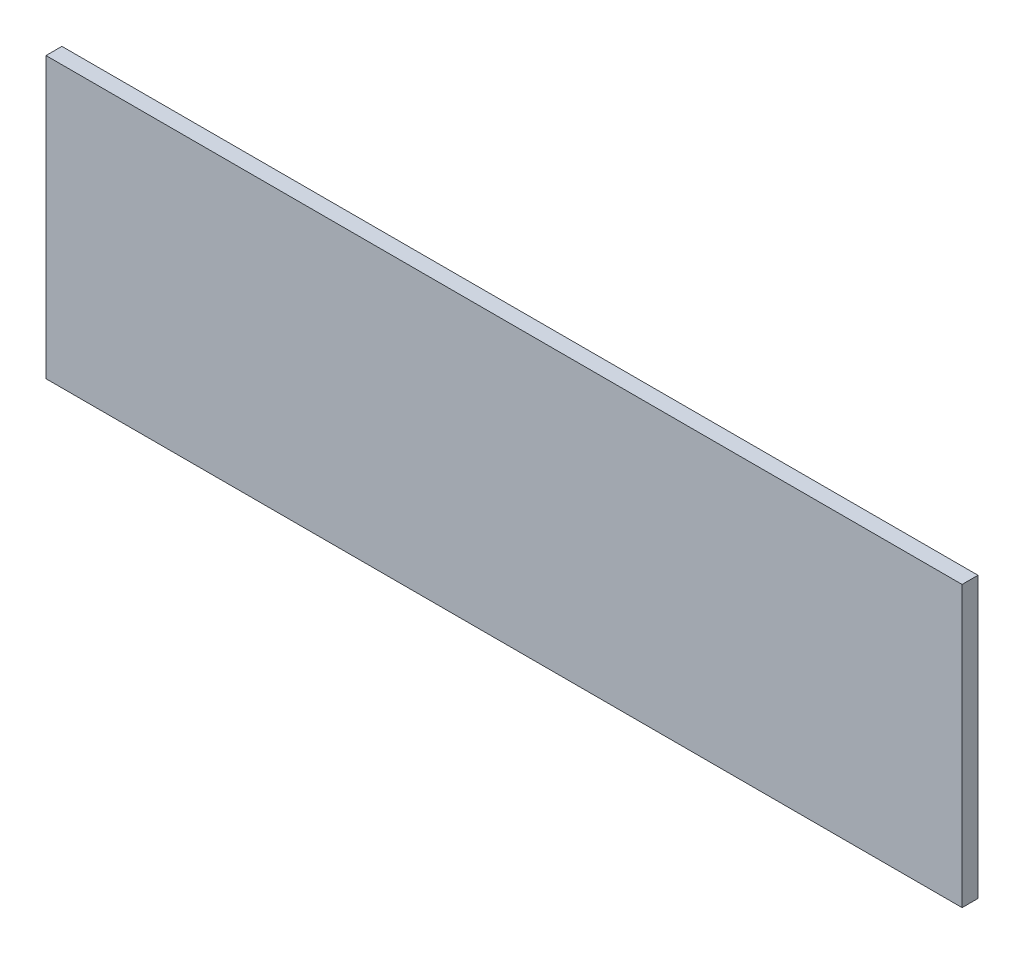
from build123d import *

# Parameters (mm, degrees)
SKETCH1_W           = 720
SKETCH1_H           = 220
BOSS_EXTRUDE1_DEPTH = 12.5


with BuildPart() as part:
    # Sketch1 → Boss-Extrude1 (new body)
    with BuildSketch(Plane.XY):
        Rectangle(SKETCH1_W, SKETCH1_H)
    extrude(amount=BOSS_EXTRUDE1_DEPTH)


solid = part.part
